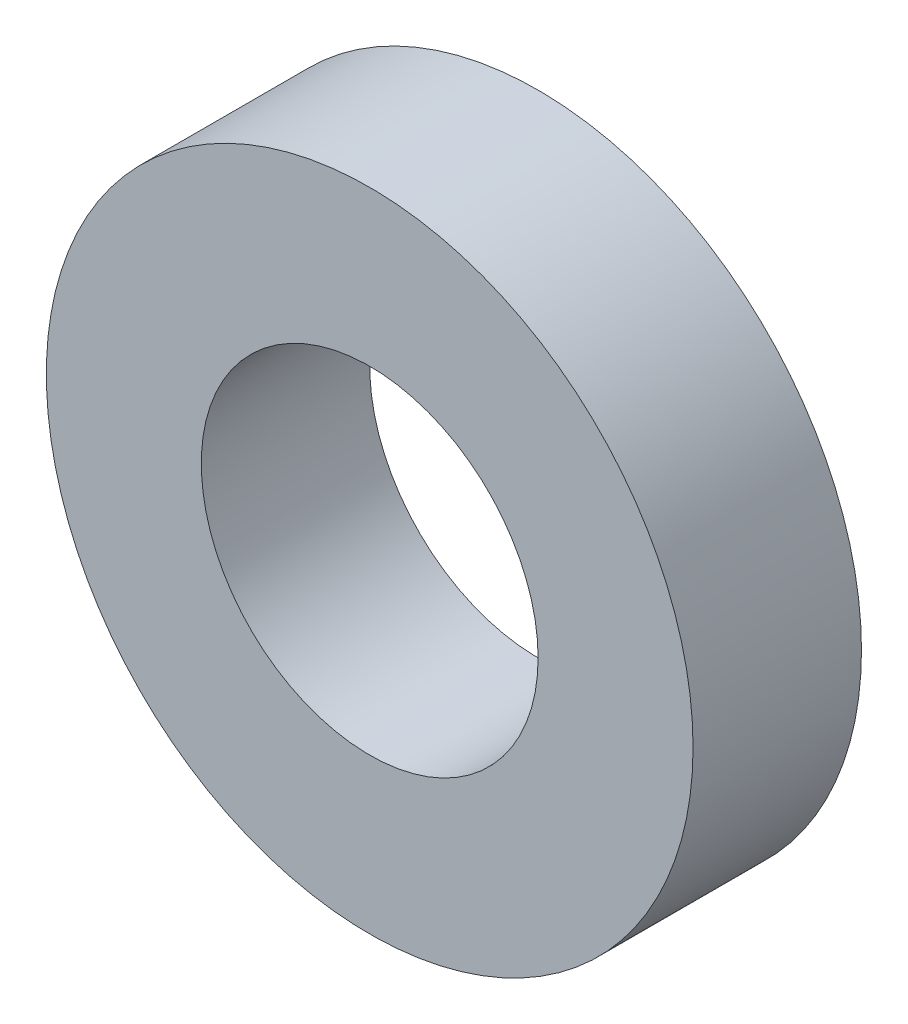
from build123d import *

# Parameters (mm, degrees)
SKETCH1_R           = 9.6
BOSS_EXTRUDE1_DEPTH = 5
SKETCH2_R           = 5
CUT_EXTRUDE1_DEPTH  = 5


with BuildPart() as part:
    # Sketch1 → Boss-Extrude1 (new body)
    with BuildSketch(Plane.XY):
        Circle(SKETCH1_R)
    extrude(amount=BOSS_EXTRUDE1_DEPTH)

    # Sketch2 → Cut-Extrude1 (cut)
    with BuildSketch(Plane.XY.offset(5)):
        Circle(SKETCH2_R)
    extrude(amount=-CUT_EXTRUDE1_DEPTH, mode=Mode.SUBTRACT)


solid = part.part
